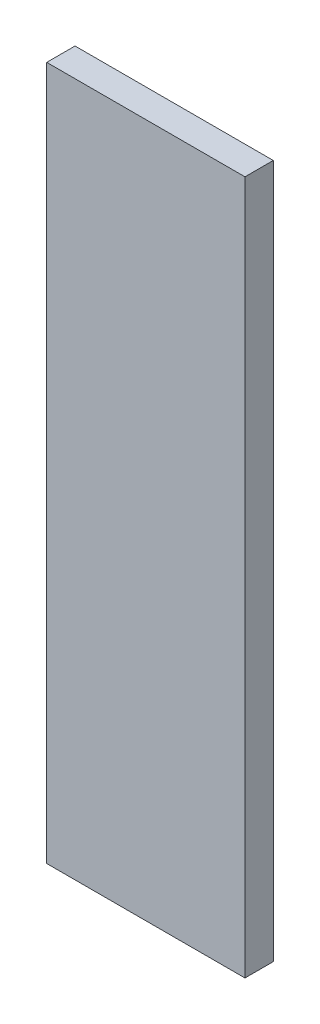
from build123d import *

# Parameters (mm, degrees)
ESQUISSE1_W        = 70
ESQUISSE1_H        = 245
BOSS_EXTRU_1_DEPTH = 10


with BuildPart() as part:
    # Esquisse1 → Boss.-Extru.1 (new body)
    with BuildSketch(Plane.XY):
        with Locations((-6.017076503, -105.583333333)):
            Rectangle(ESQUISSE1_W, ESQUISSE1_H)
    extrude(amount=BOSS_EXTRU_1_DEPTH)


solid = part.part
